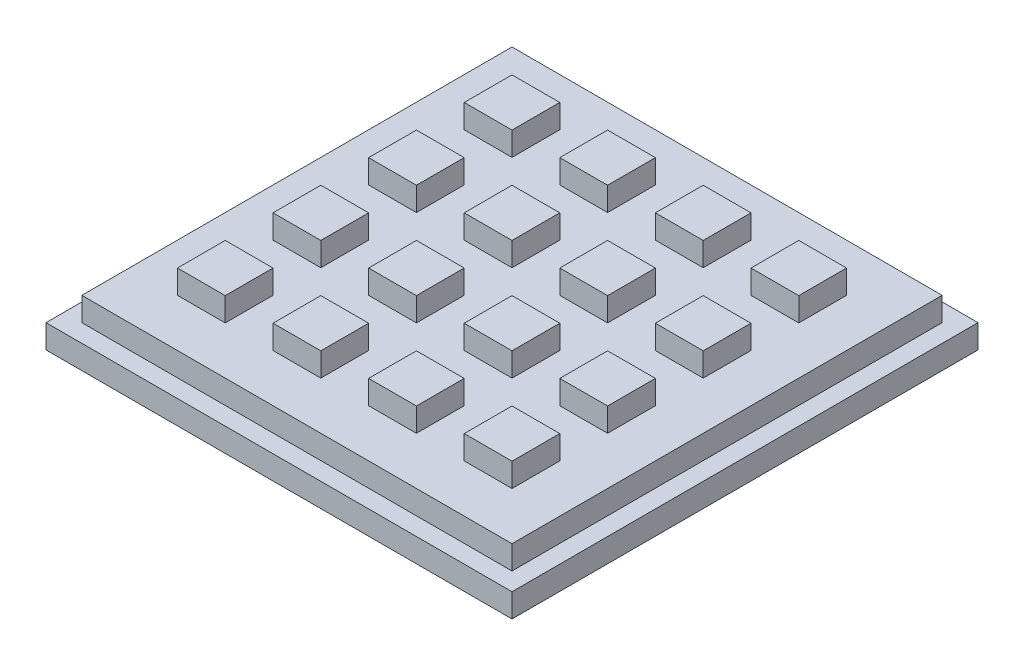
from build123d import *

# Parameters (mm, degrees)
SKETCH1_W           = 65
SKETCH1_H           = 65
BOSS_EXTRUDE1_DEPTH = 3.3
SKETCH2_W           = 60
SKETCH2_H           = 60
BOSS_EXTRUDE2_DEPTH = 3.3
SKETCH3_W           = 6.666666666
SKETCH3_H           = 6.666666666
SKETCH3_W_2         = 6.666666667
BOSS_EXTRUDE3_DEPTH = 3.3
LPATTERN1_COUNT     = 4
LPATTERN1_PITCH     = 13.3333334


with BuildPart() as part:
    # Sketch1 → Boss-Extrude1 (new body)
    with BuildSketch(Plane(origin=(0, 0, 0), x_dir=(1, 0, 0), z_dir=(0, 1, 0))):
        with Locations((32.5, 32.5)):
            Rectangle(SKETCH1_W, SKETCH1_H)
    extrude(amount=BOSS_EXTRUDE1_DEPTH)

    # Sketch2 → Boss-Extrude2 (add)
    with BuildSketch(Plane(origin=(0, 3.3, 0), x_dir=(1, 0, 0), z_dir=(0, 1, 0))):
        with Locations((32.5, 32.5)):
            Rectangle(SKETCH2_W, SKETCH2_H)
    extrude(amount=BOSS_EXTRUDE2_DEPTH)

    # Sketch3 → Boss-Extrude3 (add)
    with BuildSketch(Plane(origin=(0, 6.6, 0), x_dir=(1, 0, 0), z_dir=(0, 1, 0))):
        with Locations((12.5, 52.5)):
            Rectangle(SKETCH3_W, SKETCH3_H)
        with Locations((25.833333334, 52.5)):
            Rectangle(SKETCH3_W_2, SKETCH3_H)
        with Locations((39.166666666, 52.5)):
            Rectangle(SKETCH3_W_2, SKETCH3_H)
        with Locations((52.5, 52.5)):
            Rectangle(SKETCH3_W, SKETCH3_H)
    boss_extrude3 = extrude(amount=BOSS_EXTRUDE3_DEPTH)

    # LPattern1: Boss-Extrude3 ×4
    with Locations(*[(0, 0, i * LPATTERN1_PITCH) for i in range(1, LPATTERN1_COUNT)]):
        add(boss_extrude3)


solid = part.part
